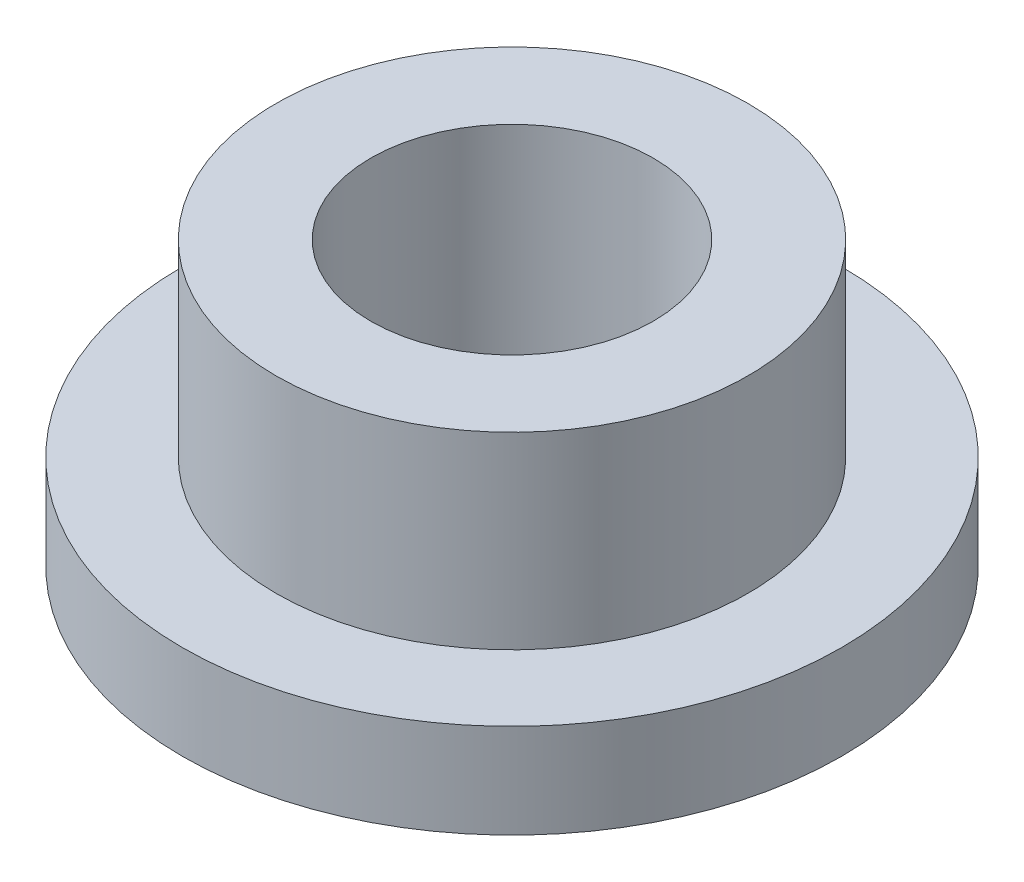
from build123d import *

# Parameters (mm, degrees)
SKETCH2_R           = 5.01
SKETCH2_R_2         = 3
BOSS_EXTRUDE1_DEPTH = 6
SKETCH3_R           = 7
SKETCH3_R_2         = 5.01
BOSS_EXTRUDE2_DEPTH = 2


with BuildPart() as part:
    # Sketch2 → Boss-Extrude1 (new body)
    with BuildSketch(Plane(origin=(0, 0, 0), x_dir=(1, 0, 0), z_dir=(0, 1, 0))):
        Circle(SKETCH2_R)
        Circle(SKETCH2_R_2, mode=Mode.SUBTRACT)
    extrude(amount=BOSS_EXTRUDE1_DEPTH)

    # Sketch3 → Boss-Extrude2 (add)
    with BuildSketch(Plane(origin=(0, 0, 0), x_dir=(1, 0, 0), z_dir=(0, 1, 0))):
        Circle(SKETCH3_R)
        Circle(SKETCH3_R_2, mode=Mode.SUBTRACT)
    extrude(amount=BOSS_EXTRUDE2_DEPTH)


solid = part.part
